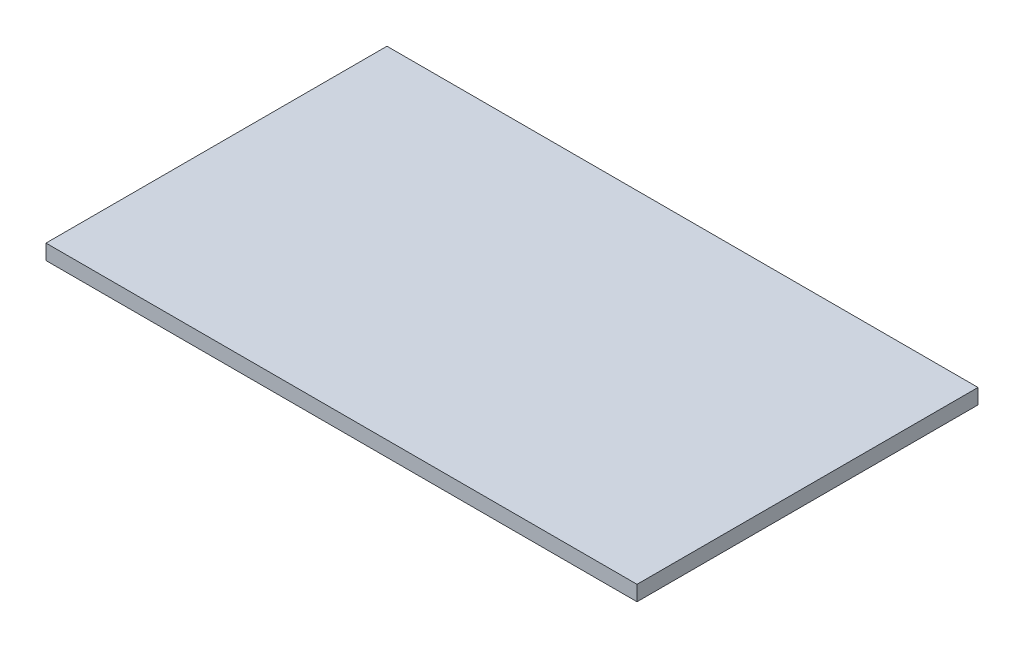
from build123d import *

# Parameters (mm, degrees)
CROQUIS1_W              = 780
CROQUIS1_H              = 450
SALIENTE_EXTRUIR1_DEPTH = 20


with BuildPart() as part:
    # Croquis1 → Saliente-Extruir1 (new body)
    with BuildSketch(Plane(origin=(0, 0, 0), x_dir=(1, 0, 0), z_dir=(0, 1, 0))):
        Rectangle(CROQUIS1_W, CROQUIS1_H)
    extrude(amount=SALIENTE_EXTRUIR1_DEPTH)


solid = part.part
